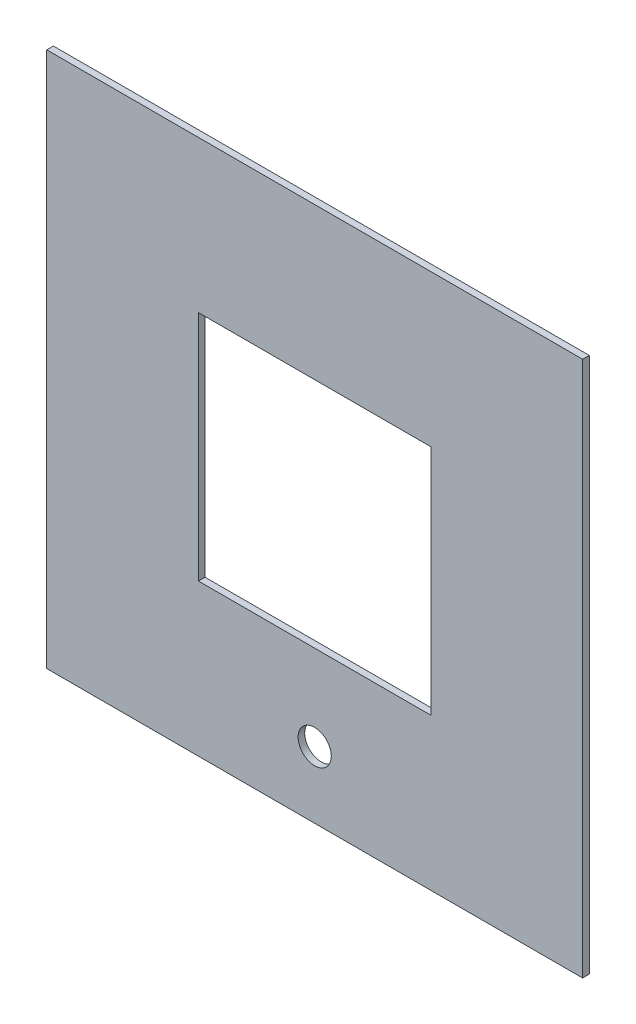
from build123d import *

# Parameters (mm, degrees)
SKETCH1_W           = 242
SKETCH1_H           = 242
SKETCH1_W_2         = 105
SKETCH1_H_2         = 105
BOSS_EXTRUDE1_DEPTH = 3
CUT_EXTRUDE1_REACH  = 5
SKETCH2_R           = 7.5


with BuildPart() as part:
    # Sketch1 → Boss-Extrude1 (new body)
    with BuildSketch(Plane.XY):
        Rectangle(SKETCH1_W, SKETCH1_H)
        Rectangle(SKETCH1_W_2, SKETCH1_H_2, mode=Mode.SUBTRACT)
    extrude(amount=BOSS_EXTRUDE1_DEPTH)

    # Sketch2 → Cut-Extrude1 (cut, up to next)
    with BuildSketch(Plane.XY.offset(3), mode=Mode.PRIVATE) as cut_extrude1_sk1:
        with Locations((0, -91)):
            Circle(SKETCH2_R)
    cut_extrude1_tool1 = extrude(cut_extrude1_sk1.sketch, amount=-CUT_EXTRUDE1_REACH, mode=Mode.PRIVATE) & part.part
    add(cut_extrude1_tool1.solids().sort_by_distance((0, -91, 3))[0], mode=Mode.SUBTRACT)


solid = part.part
